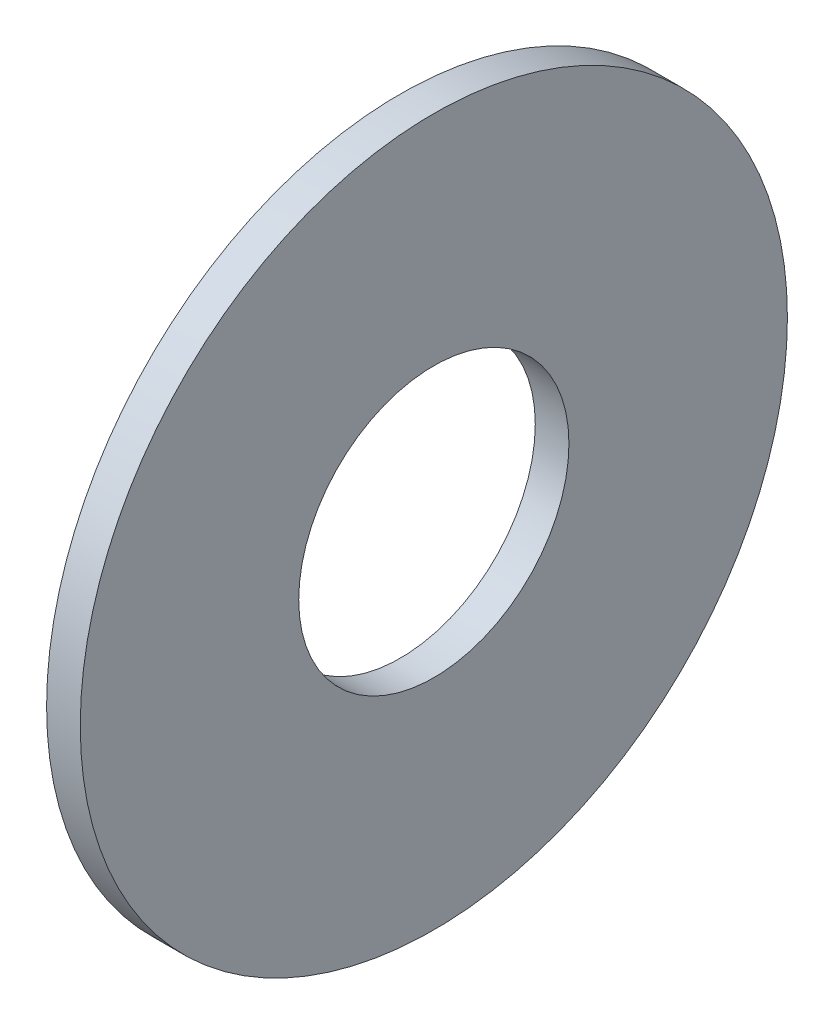
from build123d import *

# Parameters (mm, degrees)
SKETCH3_R                = 10.5
SKETCH3_R_2              = 4.0125
BOSS_EXTRUDE1_DEPTH      = 0.5
BOSS_EXTRUDE1_DEPTH_BACK = 0.5


with BuildPart() as part:
    # Sketch3 → Boss-Extrude1 (new body, two sides)
    with BuildSketch(Plane(origin=(0, 0, 0), x_dir=(0, 0, -1), z_dir=(1, 0, 0))) as boss_extrude1_sk:
        Circle(SKETCH3_R)
        Circle(SKETCH3_R_2, mode=Mode.SUBTRACT)
    extrude(amount=BOSS_EXTRUDE1_DEPTH)
    extrude(boss_extrude1_sk.sketch, amount=-BOSS_EXTRUDE1_DEPTH_BACK)


solid = part.part
